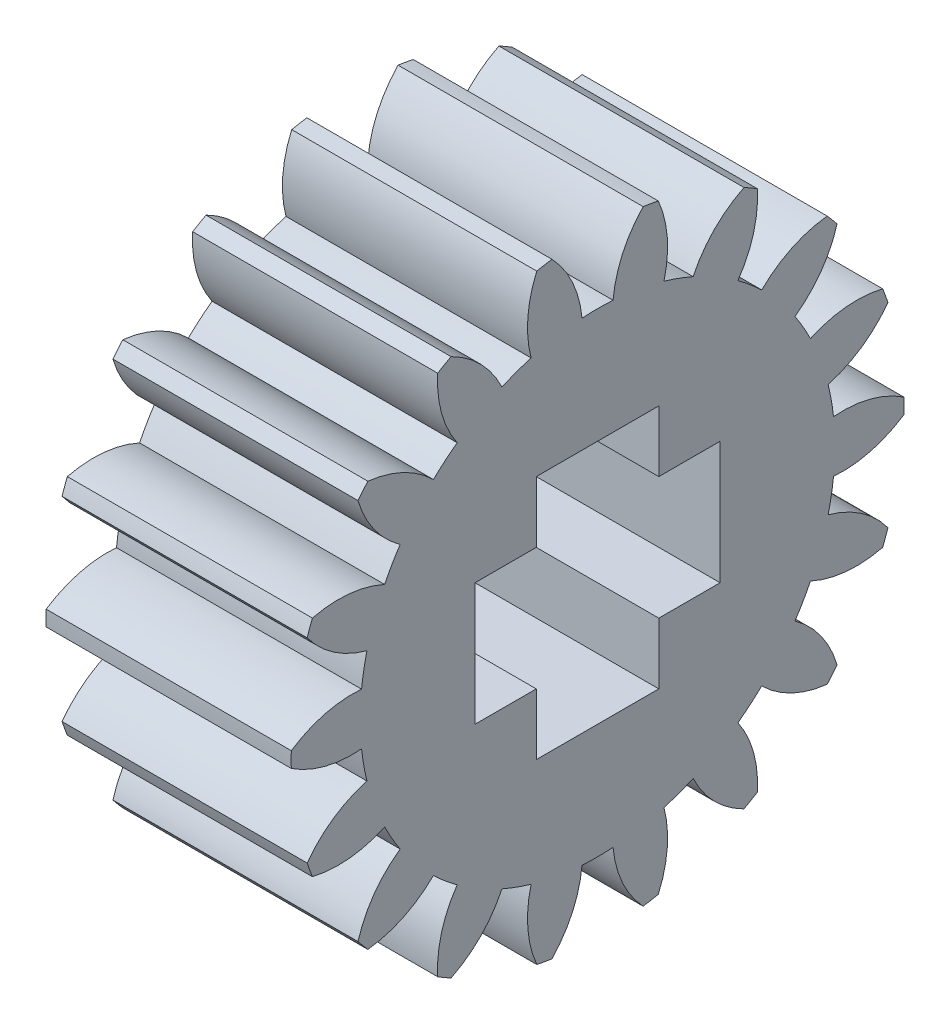
from build123d import *

# Parameters (mm, degrees)
BASPROSKE_W        = 12
BASPROSKE_H        = 15
TOOTHCUT_DEPTH     = 25.372115214
TEETHCUTS_COUNT    = 18
TEETHCUTS_ANGLE    = 340
BORSKE_R           = 2
BORE_DEPTH         = 50.0000508
SKETCH2_W          = 3
SKETCH2_H          = 6
SKETCH2_W_2        = 6
SKETCH2_H_2        = 3
CUT_EXTRUDE2_DEPTH = 16


with BuildPart() as part:
    # BasProSke → Base-Revolve (revolve)
    with BuildSketch(Plane(origin=(0, 0, 0), x_dir=(1, 0, 0), z_dir=(0, 1, 0)), mode=Mode.PRIVATE) as base_revolve_sk:
        with Locations((6, 7.5)):
            Rectangle(BASPROSKE_W, BASPROSKE_H)
    revolve(base_revolve_sk.sketch.rotate(Axis((-10, 0, 0), (1, 0, 0)), 180), axis=Axis((-10, 0, 0), (1, 0, 0)))

    # TooCutSke → ToothCut (cut, through all)
    with BuildSketch(Plane(origin=(0, 0, 0), x_dir=(0, 0, -1), z_dir=(1, 0, 0))):
        with BuildLine():
            ThreePointArc((0.759974923, 11.599129886), (0, 11.624), (-0.759974923, 11.599129886))
            ThreePointArc((-0.759974923, 11.599129886), (-1.229186471, 13.354767823), (-2.254227748, 14.855339189))
            ThreePointArc((-2.254227748, 14.855339189), (0, 15.0254), (2.254227748, 14.855339189))
            ThreePointArc((2.254227748, 14.855339189), (1.229186471, 13.354767823), (0.759974923, 11.599129886))
        make_face()
    toothcut = extrude(amount=TOOTHCUT_DEPTH, mode=Mode.SUBTRACT)

    # TeethCuts: ToothCut ×18 about axis
    teethcuts_axis = Axis((-10, 0, 0), (1, 0, 0))
    for i in range(1, TEETHCUTS_COUNT):
        add(toothcut.rotate(teethcuts_axis, i * TEETHCUTS_ANGLE / (TEETHCUTS_COUNT - 1)), mode=Mode.SUBTRACT)

    # BorSke → Bore (cut, symmetric)
    with BuildSketch(Plane(origin=(0, 0, 0), x_dir=(0, 0, -1), z_dir=(1, 0, 0))):
        with Locations(Location((0, 0, 0), (0, 0, 180))):
            Circle(BORSKE_R)
    extrude(amount=BORE_DEPTH, both=True, mode=Mode.SUBTRACT)

    # Sketch2 → Cut-Extrude2 (cut)
    with BuildSketch(Plane(origin=(12, 0, 0), x_dir=(0, 0, -1), z_dir=(1, 0, 0))):
        with Locations((-4.5, 0)):
            Rectangle(SKETCH2_W, SKETCH2_H)
        with Locations((0, 4.5)):
            Rectangle(SKETCH2_W_2, SKETCH2_H_2)
        Rectangle(SKETCH2_W_2, SKETCH2_H)
        with Locations((4.5, 0)):
            Rectangle(SKETCH2_W, SKETCH2_H)
        with Locations((0, -4.5)):
            Rectangle(SKETCH2_W_2, SKETCH2_H_2)
    extrude(amount=-CUT_EXTRUDE2_DEPTH, mode=Mode.SUBTRACT)


solid = part.part
